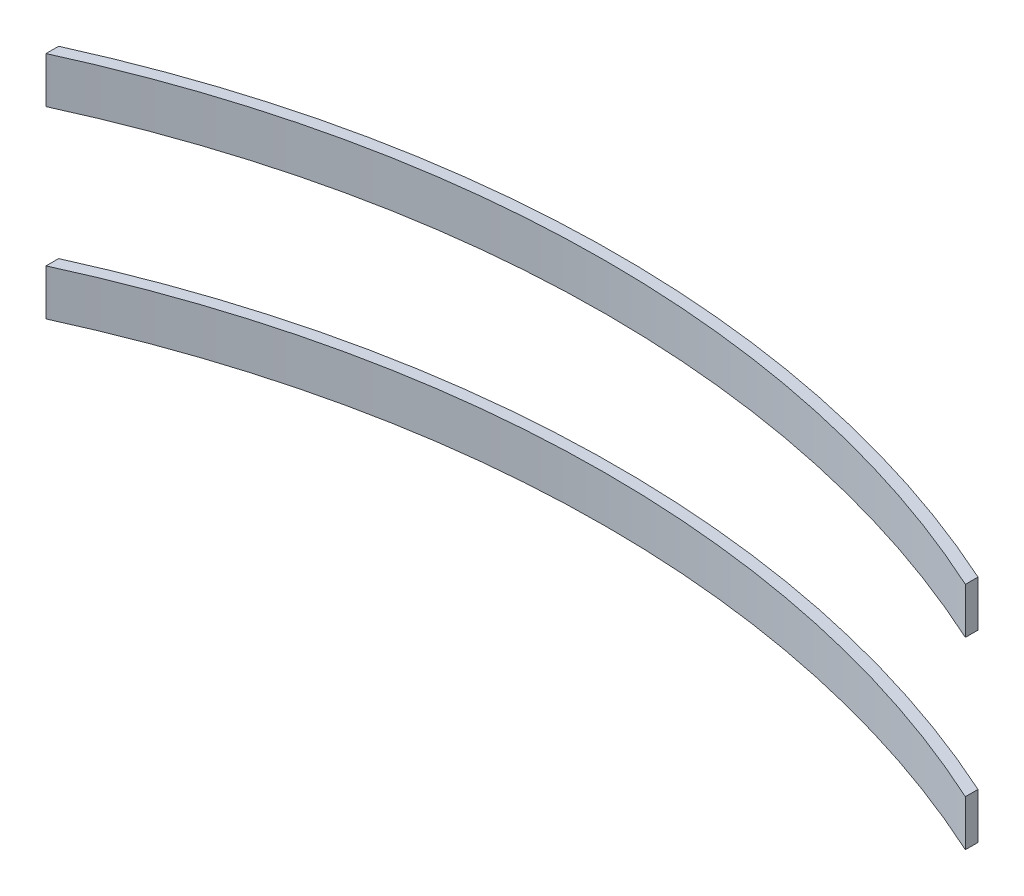
from build123d import *

# Parameters (mm, degrees)
BOSS_EXTRUDE1_DEPTH = 2
BOSS_EXTRUDE2_DEPTH = 2


with BuildPart() as part:
    # Sketch9 → Boss-Extrude1 (new body)
    with BuildSketch(Plane(origin=(0, 0, 0), x_dir=(1, 0, 0), z_dir=(0, 1, 0))):
        with BuildLine():
            Line((-20, 44.18427322), (-20, 43.634848459))
            ThreePointArc((-20, 43.634848459), (0, 48), (20, 43.634848459))
            Line((20, 43.634848459), (20, 44.18427322))
            ThreePointArc((20, 44.18427322), (0, 48.5), (-20, 44.18427322))
        make_face()
    extrude(amount=BOSS_EXTRUDE1_DEPTH)


with BuildPart() as body_2:
    # Sketch11 → Boss-Extrude2 (new body)
    with BuildSketch(Plane(origin=(0, 8, 0), x_dir=(1, 0, 0), z_dir=(0, 1, 0))):
        with BuildLine():
            Line((20, 44.18427322), (20, 43.634848459))
            ThreePointArc((20, 43.634848459), (0, 48), (-20, 43.634848459))
            Line((-20, 43.634848459), (-20, 44.18427322))
            ThreePointArc((-20, 44.18427322), (0, 48.5), (20, 44.18427322))
        make_face()
    extrude(amount=BOSS_EXTRUDE2_DEPTH)


solid = Compound([part.part, body_2.part])
